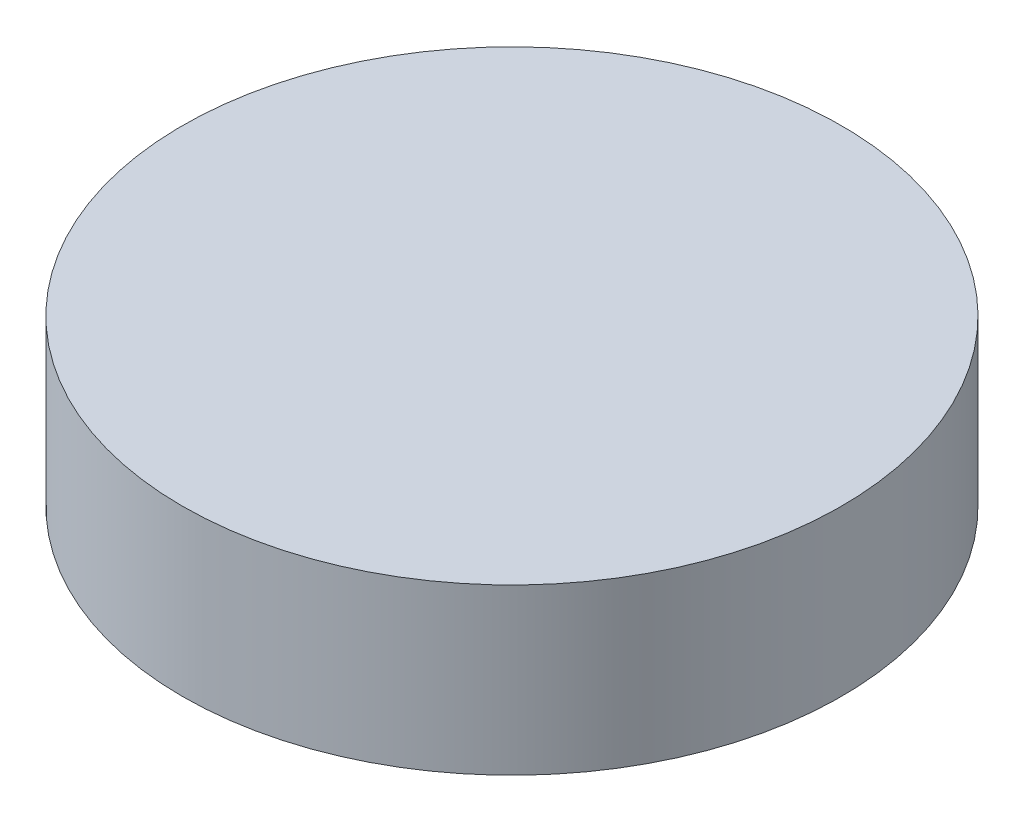
from build123d import *

# Parameters (mm, degrees)
SKETCH1_R           = 20
BOSS_EXTRUDE1_DEPTH = 10


with BuildPart() as part:
    # Sketch1 → Boss-Extrude1 (new body)
    with BuildSketch(Plane(origin=(0, 0, 0), x_dir=(1, 0, 0), z_dir=(0, 1, 0))):
        Circle(SKETCH1_R)
    extrude(amount=BOSS_EXTRUDE1_DEPTH)


solid = part.part
